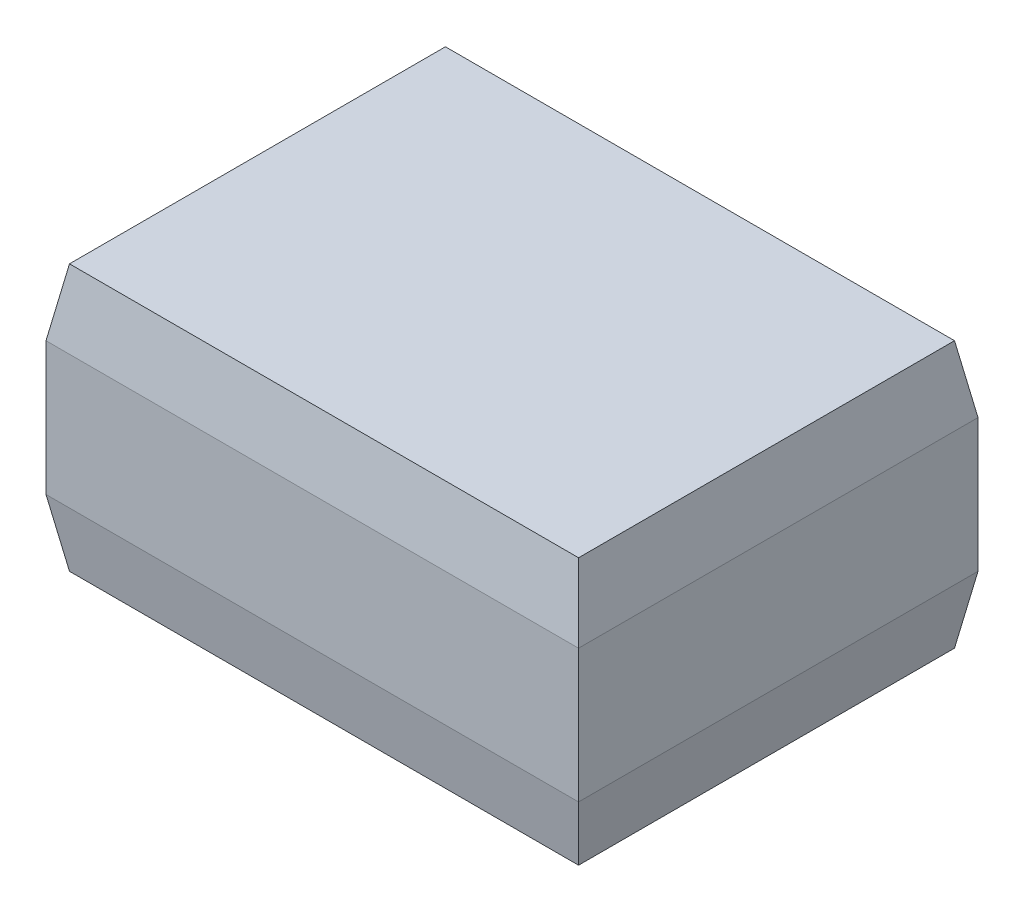
from build123d import *

# Parameters (mm, degrees)
ESQUISSE1_W             = 4
ESQUISSE1_H             = 3
EXTRUSION1_DEPTH        = 2
CHANFREIN1_SIZE         = 0.5
CHANFREIN1_SIZE2        = 0.08816349
CHANFREIN2_SIZE         = 0.5
CHANFREIN2_SIZE2        = 0.08816349
CHANFREIN3_SIZE         = 0.5
CHANFREIN3_SIZE2        = 0.08816349
CHANFREIN3_PART_2_SIZE  = 0.5
CHANFREIN3_PART_2_SIZE2 = 0.08816349
CHANFREIN4_SIZE         = 0.5
CHANFREIN4_SIZE2        = 0.08816349
CHANFREIN5_SIZE         = 0.5
CHANFREIN5_SIZE2        = 0.08816349
CHANFREIN5_PART_2_SIZE  = 0.5
CHANFREIN5_PART_2_SIZE2 = 0.08816349
CHANFREIN5_PART_3_SIZE  = 0.5
CHANFREIN5_PART_3_SIZE2 = 0.08816349


with BuildPart() as part:
    # Esquisse1 → Extrusion1 (new body)
    with BuildSketch(Plane(origin=(0, 0, 0), x_dir=(1, 0, 0), z_dir=(0, 1, 0))):
        with Locations((2, 1.5)):
            Rectangle(ESQUISSE1_W, ESQUISSE1_H)
    extrude(amount=EXTRUSION1_DEPTH)

    # Chanfrein1
    chanfrein1_edges = [part.edges().sort_by_distance(p)[0] for p in [
        (4, 2, -1.5),
    ]]
    chanfrein1_side = [part.faces().sort_by_distance(p)[0] for p in [
        (4, 1, -1.5),
    ]]
    chamfer(chanfrein1_edges, length=CHANFREIN1_SIZE, length2=CHANFREIN1_SIZE2, reference=chanfrein1_side[0])

    # Chanfrein2
    chanfrein2_edges = [part.edges().sort_by_distance(p)[0] for p in [
        (0, 2, -1.5),
    ]]
    chanfrein2_side = [part.faces().sort_by_distance(p)[0] for p in [
        (0, 1, -1.5),
    ]]
    chamfer(chanfrein2_edges, length=CHANFREIN2_SIZE, length2=CHANFREIN2_SIZE2, reference=chanfrein2_side[0])

    # Chanfrein3
    chanfrein3_edges = [part.edges().sort_by_distance(p)[0] for p in [
        (2, 2, -3),
    ]]
    chanfrein3_side = [part.faces().sort_by_distance(p)[0] for p in [
        (2, 0.995382709, -3),
    ]]
    chamfer(chanfrein3_edges, length=CHANFREIN3_SIZE, length2=CHANFREIN3_SIZE2, reference=chanfrein3_side[0])

    # Chanfrein3 part 2
    chanfrein3_part_2_edges = [part.edges().sort_by_distance(p)[0] for p in [
        (2, 2, 0),
    ]]
    chanfrein3_part_2_side = [part.faces().sort_by_distance(p)[0] for p in [
        (2, 0.995382709, 0),
    ]]
    chamfer(chanfrein3_part_2_edges, length=CHANFREIN3_PART_2_SIZE, length2=CHANFREIN3_PART_2_SIZE2, reference=chanfrein3_part_2_side[0])

    # Chanfrein4
    chanfrein4_edges = [part.edges().sort_by_distance(p)[0] for p in [
        (4, 0, -1.5),
    ]]
    chanfrein4_side = [part.faces().sort_by_distance(p)[0] for p in [
        (4, 0.75, -1.5),
    ]]
    chamfer(chanfrein4_edges, length=CHANFREIN4_SIZE, length2=CHANFREIN4_SIZE2, reference=chanfrein4_side[0])

    # Chanfrein5
    chanfrein5_edges = [part.edges().sort_by_distance(p)[0] for p in [
        (1.955918255, 0, -3),
    ]]
    chanfrein5_side = [part.faces().sort_by_distance(p)[0] for p in [
        (1.992734308, 0.752150763, -3),
    ]]
    chamfer(chanfrein5_edges, length=CHANFREIN5_SIZE, length2=CHANFREIN5_SIZE2, reference=chanfrein5_side[0])

    # Chanfrein5 part 2
    chanfrein5_part_2_edges = [part.edges().sort_by_distance(p)[0] for p in [
        (0, 0, -1.5),
    ]]
    chanfrein5_part_2_side = [part.faces().sort_by_distance(p)[0] for p in [
        (0, 0.75, -1.5),
    ]]
    chamfer(chanfrein5_part_2_edges, length=CHANFREIN5_PART_2_SIZE, length2=CHANFREIN5_PART_2_SIZE2, reference=chanfrein5_part_2_side[0])

    # Chanfrein5 part 3
    chanfrein5_part_3_edges = [part.edges().sort_by_distance(p)[0] for p in [
        (1.955918255, 0, 0),
    ]]
    chanfrein5_part_3_side = [part.faces().sort_by_distance(p)[0] for p in [
        (1.992734308, 0.752150763, 0),
    ]]
    chamfer(chanfrein5_part_3_edges, length=CHANFREIN5_PART_3_SIZE, length2=CHANFREIN5_PART_3_SIZE2, reference=chanfrein5_part_3_side[0])


solid = part.part
